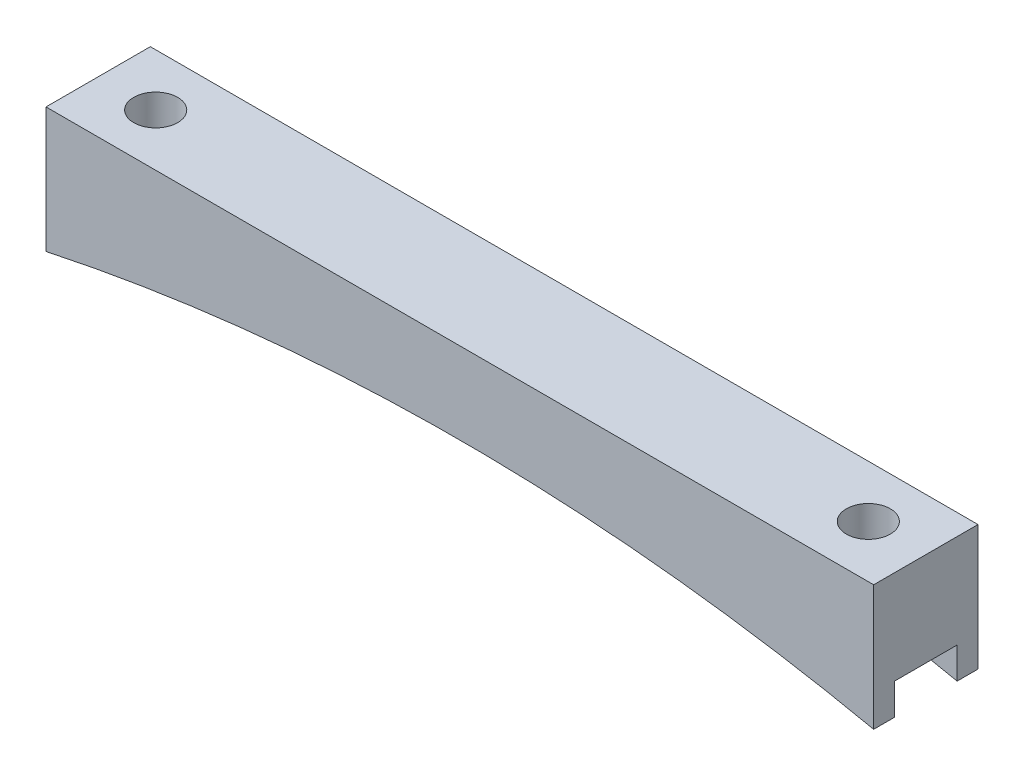
from build123d import *

# Parameters (mm, degrees)
BOSS_EXTRUDE1_DEPTH = 12.7
SKETCH2_R           = 2.675
CUT_EXTRUDE1_DEPTH  = 16.24
SKETCH3_W           = 7.62
SKETCH3_H           = 3.81
CUT_EXTRUDE2_DEPTH  = 101.7400001


with BuildPart() as part:
    # Sketch1 → Boss-Extrude1 (new body)
    with BuildSketch(Plane.XY):
        with BuildLine():
            Line((-50.37, 0), (50.37, 0))
            Line((50.37, 0), (50.37, -15.24))
            ThreePointArc((50.37, -15.24), (0, -9.924222142), (-50.37, -15.24))
            Line((-50.37, -15.24), (-50.37, 0))
        make_face()
    extrude(amount=BOSS_EXTRUDE1_DEPTH)

    # Sketch2 → Cut-Extrude1 (cut, through all)
    with BuildSketch(Plane(origin=(0, 0, 0), x_dir=(1, 0, 0), z_dir=(0, 1, 0))):
        with Locations((-43.37, -6.35)):
            Circle(SKETCH2_R)
        with Locations((43.37, -6.35)):
            Circle(SKETCH2_R)
    extrude(amount=-CUT_EXTRUDE1_DEPTH, mode=Mode.SUBTRACT)

    # Sketch3 → Cut-Extrude2 (cut, through all)
    with BuildSketch(Plane(origin=(50.37, 0, 0), x_dir=(0, 0, -1), z_dir=(1, 0, 0))):
        with Locations((-6.35, -13.335)):
            Rectangle(SKETCH3_W, SKETCH3_H)
    extrude(amount=-CUT_EXTRUDE2_DEPTH, mode=Mode.SUBTRACT)


solid = part.part
